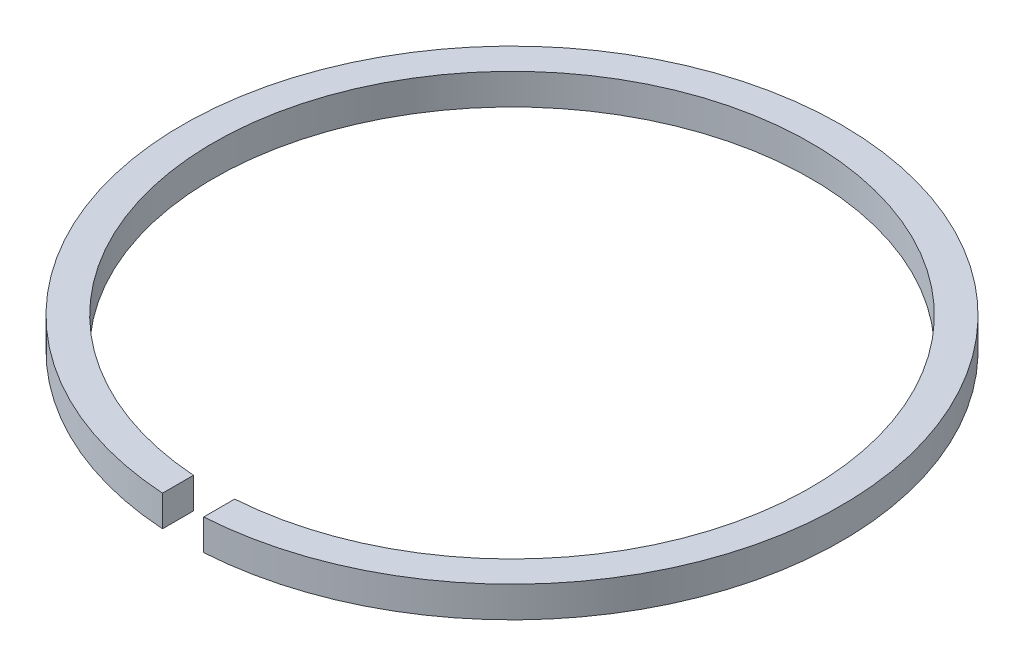
from build123d import *

# Parameters (mm, degrees)
BODY_DEPTH = 0.75


with BuildPart() as part:
    # Sketch1 → Body (new body, symmetric)
    with BuildSketch(Plane(origin=(0, 0, 0), x_dir=(1, 0, 0), z_dir=(0, 1, 0))):
        with BuildLine():
            Line((-1, -14.465476141), (-1, -15.968719423))
            ThreePointArc((-1, -15.968719423), (0, 16), (1, -15.968719423))
            Line((1, -15.968719423), (1, -14.465476141))
            ThreePointArc((1, -14.465476141), (0, 14.5), (-1, -14.465476141))
        make_face()
    extrude(amount=BODY_DEPTH, both=True)


solid = part.part
